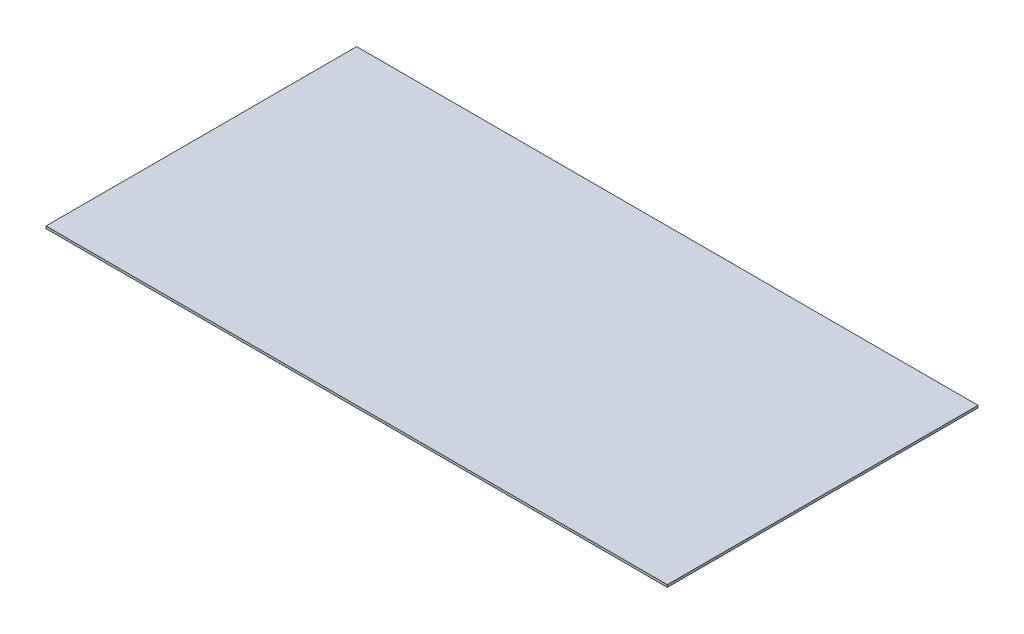
from build123d import *

# Parameters (mm, degrees)
SKETCH1_W           = 800
SKETCH1_H           = 400
BOSS_EXTRUDE1_DEPTH = 3


with BuildPart() as part:
    # Sketch1 → Boss-Extrude1 (new body)
    with BuildSketch(Plane(origin=(0, 0, 0), x_dir=(1, 0, 0), z_dir=(0, 1, 0))):
        with Locations((400, 200)):
            Rectangle(SKETCH1_W, SKETCH1_H)
    extrude(amount=BOSS_EXTRUDE1_DEPTH)


solid = part.part
